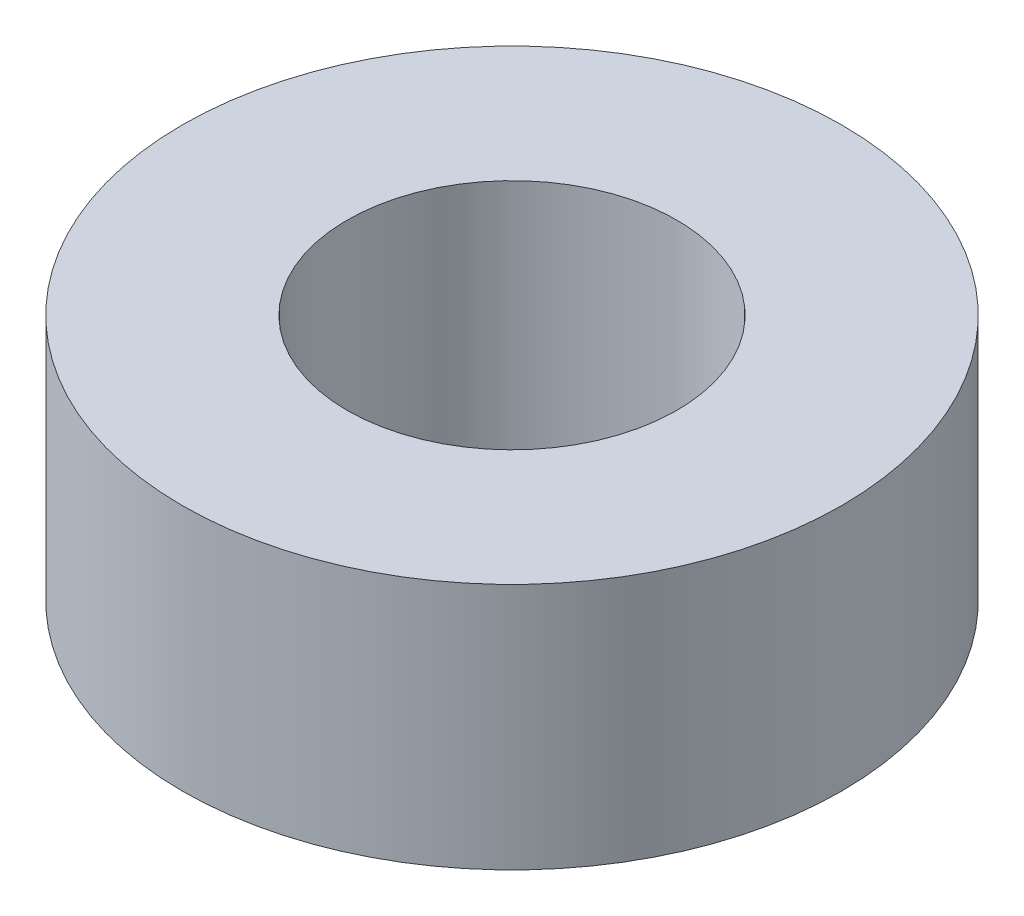
from build123d import *

# Parameters (mm, degrees)
SKETCH1_R           = 6.35
SKETCH1_R_2         = 3.175
BOSS_EXTRUDE1_DEPTH = 4.7625


with BuildPart() as part:
    # Sketch1 → Boss-Extrude1 (new body)
    with BuildSketch(Plane(origin=(0, 0, 0), x_dir=(1, 0, 0), z_dir=(0, 1, 0))):
        Circle(SKETCH1_R)
        Circle(SKETCH1_R_2, mode=Mode.SUBTRACT)
    extrude(amount=BOSS_EXTRUDE1_DEPTH)


solid = part.part
